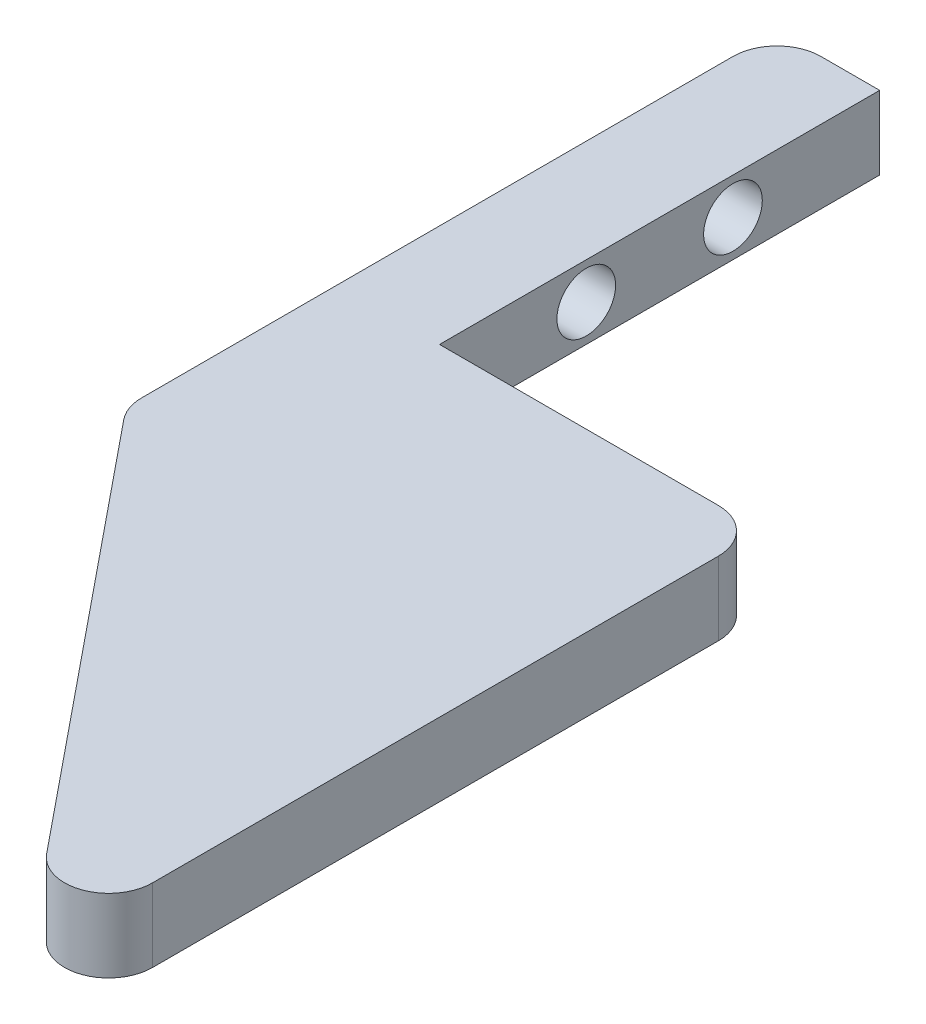
from build123d import *

# Parameters (mm, degrees)
BOSS_EXTRUDE1_DEPTH = 5
SKETCH3_R           = 2
CUT_EXTRUDE2_DEPTH  = 20
FILLET2_R           = 3
FILLET3_R           = 3
FILLET4_R           = 3


with BuildPart() as part:
    # Sketch1 → Boss-Extrude1 (new body)
    with BuildSketch(Plane(origin=(0, 0, 0), x_dir=(1, 0, 0), z_dir=(0, 1, 0))):
        Polygon((2.364942178, -62.723244455), (-26.635057822, -27.094088406), (-26.635057822, 17.276755545), (-19.635057822, 17.276755545), (-19.635057822, -12.723244455), (2.364942178, -12.723244455), align=None)
    extrude(amount=BOSS_EXTRUDE1_DEPTH)

    # Sketch3 → Cut-Extrude2 (cut)
    with BuildSketch(Plane(origin=(-19.635057822, 0, 0), x_dir=(0, 0, -1), z_dir=(1, 0, 0))):
        with Locations((-2.723244455, 2.5)):
            Circle(SKETCH3_R)
        with Locations((7.276755545, 2.5)):
            Circle(SKETCH3_R)
    extrude(amount=-CUT_EXTRUDE2_DEPTH, mode=Mode.SUBTRACT)

    # Fillet2
    fillet2_edges = [part.edges().sort_by_distance(p)[0] for p in [
        (2.364942178, 2.5, 62.723244455),
    ]]
    fillet(fillet2_edges, radius=FILLET2_R)

    # Fillet3
    fillet3_edges = [part.edges().sort_by_distance(p)[0] for p in [
        (2.364942178, 2.5, 12.723244455),
        (-26.635057822, 2.5, -17.276755545),
    ]]
    fillet(fillet3_edges, radius=FILLET3_R)

    # Fillet4
    fillet4_edges = [part.edges().sort_by_distance(p)[0] for p in [
        (-26.635057822, 2.5, 27.094088406),
    ]]
    fillet(fillet4_edges, radius=FILLET4_R)


solid = part.part
